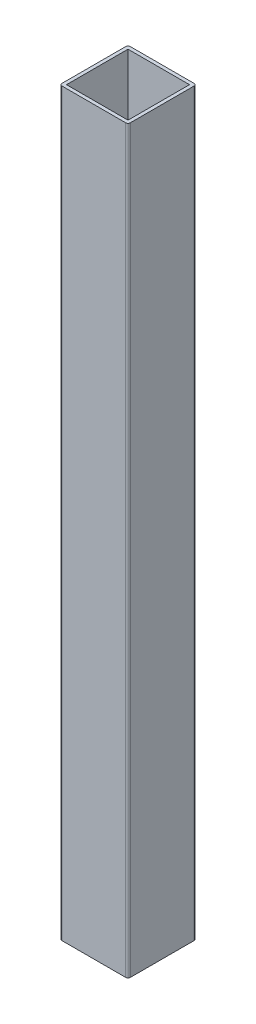
from build123d import *

# Parameters (mm, degrees)
SKETCH1_W           = 54
SKETCH1_H           = 54
BOSS_EXTRUDE1_DEPTH = 650


with BuildPart() as part:
    # Sketch1 → Boss-Extrude1 (new body)
    with BuildSketch(Plane(origin=(0, 0, 0), x_dir=(1, 0, 0), z_dir=(0, 1, 0))):
        with BuildLine():
            Line((2, 0), (58, 0))
            ThreePointArc((58, 0), (59.414213562, 0.585786438), (60, 2))
            Line((60, 2), (60, 58))
            ThreePointArc((60, 58), (59.414213562, 59.414213562), (58, 60))
            Line((58, 60), (2, 60))
            ThreePointArc((2, 60), (0.585786438, 59.414213562), (0, 58))
            Line((0, 58), (0, 2))
            ThreePointArc((0, 2), (0.585786438, 0.585786438), (2, 0))
        make_face()
        with Locations((30, 30)):
            Rectangle(SKETCH1_W, SKETCH1_H, mode=Mode.SUBTRACT)
    extrude(amount=BOSS_EXTRUDE1_DEPTH)


solid = part.part
